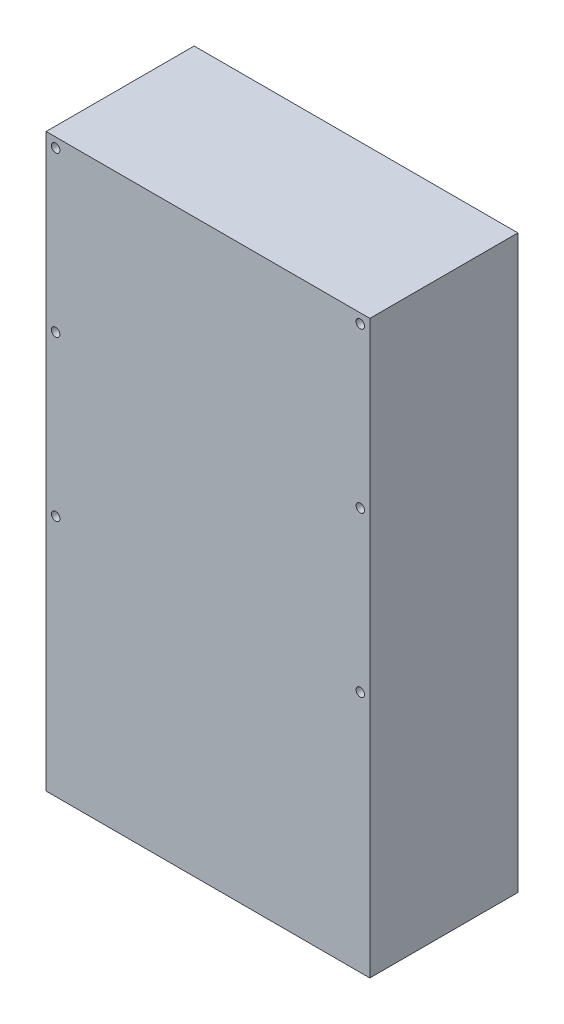
from build123d import *

# Parameters (mm, degrees)
SKETCH1_W           = 86.36
SKETCH1_H           = 152.4
SKETCH1_R           = 1.1303
BOSS_EXTRUDE1_DEPTH = 39.497


with BuildPart() as part:
    # Sketch1 → Boss-Extrude1 (new body)
    with BuildSketch(Plane.XY):
        with Locations((0, -141.428063314)):
            Rectangle(SKETCH1_W, SKETCH1_H)
        with Locations((40.64, -67.768063314)):
            Circle(SKETCH1_R, mode=Mode.SUBTRACT)
        with Locations((40.64, -110.313063314)):
            Circle(SKETCH1_R, mode=Mode.SUBTRACT)
        with Locations((40.64, -152.858063314)):
            Circle(SKETCH1_R, mode=Mode.SUBTRACT)
        with Locations((-40.64, -152.858063314)):
            Circle(SKETCH1_R, mode=Mode.SUBTRACT)
        with Locations((-40.64, -110.313063314)):
            Circle(SKETCH1_R, mode=Mode.SUBTRACT)
        with Locations((-40.64, -67.768063314)):
            Circle(SKETCH1_R, mode=Mode.SUBTRACT)
    extrude(amount=BOSS_EXTRUDE1_DEPTH)


solid = part.part
